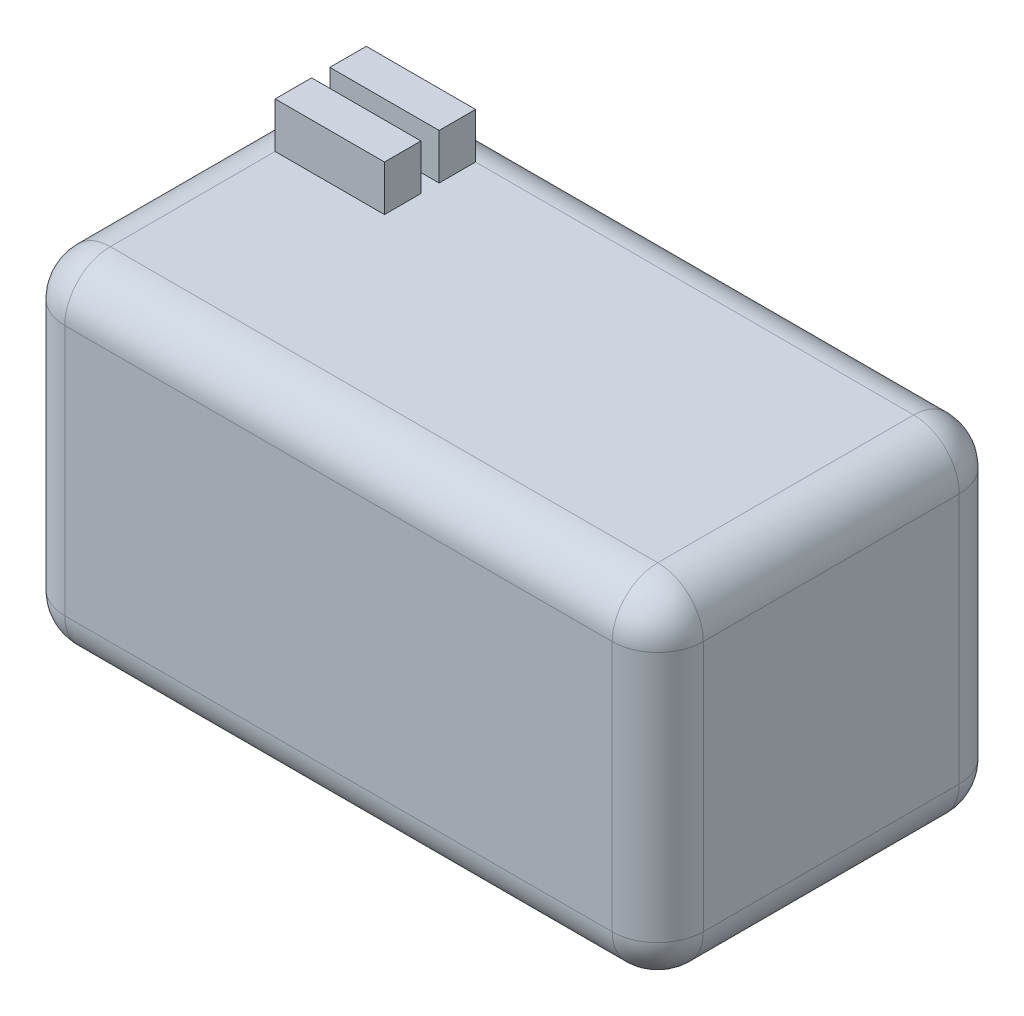
from build123d import *

# Parameters (mm, degrees)
SKETCH1_W           = 70.1
SKETCH1_H           = 37.59
BOSS_EXTRUDE1_DEPTH = 38.1
FILLET1_R           = 5
SKETCH2_W           = 12
SKETCH2_H           = 4
BOSS_EXTRUDE2_DEPTH = 5


with BuildPart() as part:
    # Sketch1 → Boss-Extrude1 (new body)
    with BuildSketch(Plane.XY):
        with Locations((6.077190332, 7.269320242)):
            Rectangle(SKETCH1_W, SKETCH1_H)
    extrude(amount=BOSS_EXTRUDE1_DEPTH)

    # Fillet1
    fillet1_edges = [part.edges().sort_by_distance(p)[0] for p in [
        (6.077190332, -11.525679758, 38.1),
        (41.127190332, 7.269320242, 38.1),
        (6.077190332, 26.064320242, 38.1),
        (41.127190332, 7.269320242, 0),
        (6.077190332, -11.525679758, 0),
        (-28.972809668, 7.269320242, 0),
        (6.077190332, 26.064320242, 0),
        (-28.972809668, 7.269320242, 38.1),
        (41.127190332, 26.064320242, 19.05),
        (41.127190332, -11.525679758, 19.05),
        (-28.972809668, -11.525679758, 19.05),
        (-28.972809668, 26.064320242, 19.05),
    ]]
    fillet(fillet1_edges, radius=FILLET1_R)

    # Sketch2 → Boss-Extrude2 (add)
    with BuildSketch(Plane(origin=(0, 26.064320242, 0), x_dir=(1, 0, 0), z_dir=(0, 1, 0))):
        with Locations((-17.972809668, -13)):
            Rectangle(SKETCH2_W, SKETCH2_H)
        with Locations((-17.972809668, -7)):
            Rectangle(SKETCH2_W, SKETCH2_H)
    extrude(amount=BOSS_EXTRUDE2_DEPTH)


solid = part.part
